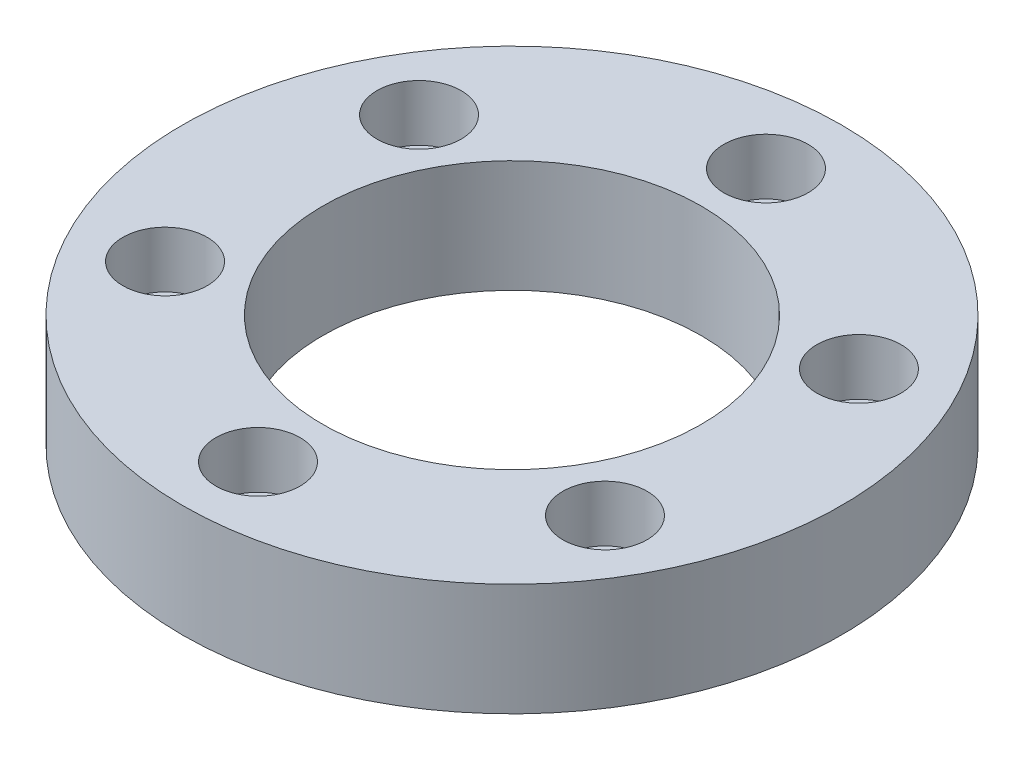
from build123d import *

# Parameters (mm, degrees)
SKETCH1_W          = 10
SKETCH1_H          = 8
SKETCH2_R          = 1.75
CUT_EXTRUDE1_DEPTH = 10
SKETCH2_3_R        = 3
SKETCH2_3_R_2      = 1.75
CUT_EXTRUDE2_DEPTH = 4


with BuildPart() as part:
    # Sketch1 → Revolve1 (revolve)
    with BuildSketch(Plane(origin=(0, 0, 0), x_dir=(0, 0, -1), z_dir=(1, 0, 0))):
        with Locations((18.485, 4)):
            Rectangle(SKETCH1_W, SKETCH1_H)
    revolve(axis=Axis((0, 0, 0), (0, 1, 0)))

    # Sketch2 → Cut-Extrude1 (cut)
    with BuildSketch(Plane(origin=(0, 8, 0), x_dir=(1, 0, 0), z_dir=(0, 1, 0))):
        with Locations((0, 18.1)):
            Circle(SKETCH2_R)
        with Locations((15.675059808, 9.05)):
            Circle(SKETCH2_R)
        with Locations((15.675059808, -9.05)):
            Circle(SKETCH2_R)
        with Locations((0, -18.1)):
            Circle(SKETCH2_R)
        with Locations((-15.675059808, -9.05)):
            Circle(SKETCH2_R)
        with Locations((-15.675059808, 9.05)):
            Circle(SKETCH2_R)
    extrude(amount=-CUT_EXTRUDE1_DEPTH, mode=Mode.SUBTRACT)

    # Sketch2_3 → Cut-Extrude2 (cut)
    # profile 1 of 6: a face of its own
    with BuildSketch(Plane(origin=(0, 8, 0), x_dir=(1, 0, 0), z_dir=(0, 1, 0))):
        with Locations((0, 18.1)):
            Circle(SKETCH2_3_R)
        with Locations((0, 18.1)):
            Circle(SKETCH2_3_R_2, mode=Mode.SUBTRACT)
    # profile 2 of 6: a face of its own
    with BuildSketch(Plane(origin=(0, 8, 0), x_dir=(1, 0, 0), z_dir=(0, 1, 0))):
        with Locations((15.675059808, 9.05)):
            Circle(SKETCH2_3_R)
        with Locations((15.675059808, 9.05)):
            Circle(SKETCH2_3_R_2, mode=Mode.SUBTRACT)
    # profile 3 of 6: a face of its own
    with BuildSketch(Plane(origin=(0, 8, 0), x_dir=(1, 0, 0), z_dir=(0, 1, 0))):
        with Locations((15.675059808, -9.05)):
            Circle(SKETCH2_3_R)
        with Locations((15.675059808, -9.05)):
            Circle(SKETCH2_3_R_2, mode=Mode.SUBTRACT)
    # profile 4 of 6: a face of its own
    with BuildSketch(Plane(origin=(0, 8, 0), x_dir=(1, 0, 0), z_dir=(0, 1, 0))):
        with Locations((0, -18.1)):
            Circle(SKETCH2_3_R)
        with Locations((0, -18.1)):
            Circle(SKETCH2_3_R_2, mode=Mode.SUBTRACT)
    # profile 5 of 6: a face of its own
    with BuildSketch(Plane(origin=(0, 8, 0), x_dir=(1, 0, 0), z_dir=(0, 1, 0))):
        with Locations((-15.675059808, -9.05)):
            Circle(SKETCH2_3_R)
        with Locations((-15.675059808, -9.05)):
            Circle(SKETCH2_3_R_2, mode=Mode.SUBTRACT)
    # profile 6 of 6: a face of its own
    with BuildSketch(Plane(origin=(0, 8, 0), x_dir=(1, 0, 0), z_dir=(0, 1, 0))):
        with Locations((-15.675059808, 9.05)):
            Circle(SKETCH2_3_R)
        with Locations((-15.675059808, 9.05)):
            Circle(SKETCH2_3_R_2, mode=Mode.SUBTRACT)
    extrude(amount=-CUT_EXTRUDE2_DEPTH, mode=Mode.SUBTRACT)


solid = part.part
